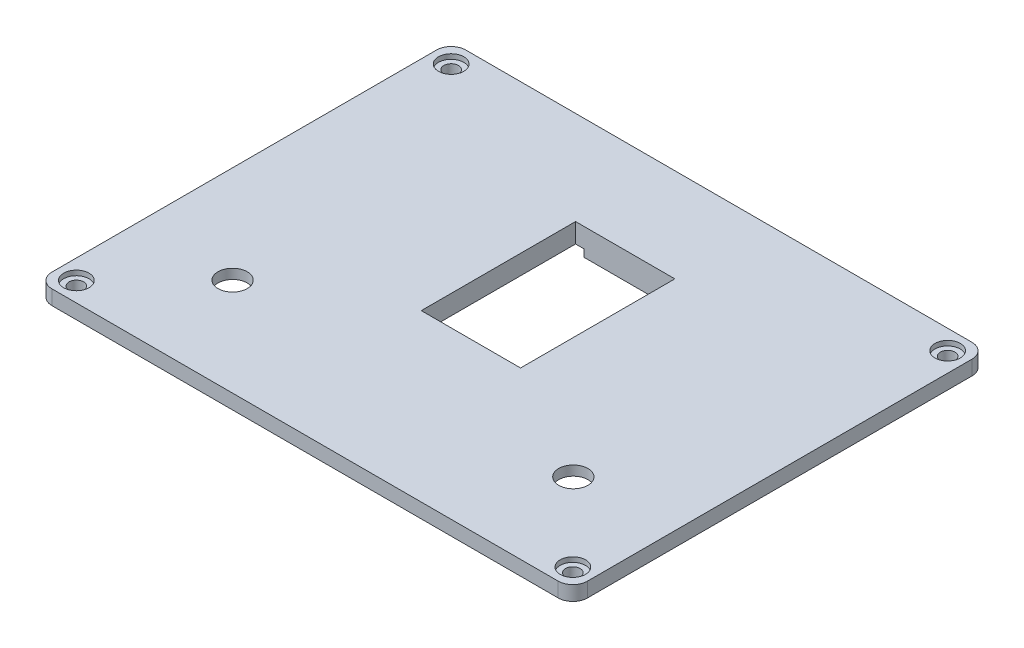
from build123d import *

# Parameters (mm, degrees)
SKETCH1_W           = 110
SKETCH1_H           = 85
BOSS_EXTRUDE1_DEPTH = 3
BOSS_EXTRUDE2_DEPTH = 1
SKETCH3_R           = 2.6
SKETCH3_R_2         = 1.5
CUT_EXTRUDE1_DEPTH  = 1
CUT_EXTRUDE2_REACH  = 6
SKETCH3_2_R         = 1.5
FILLET1_R           = 3
SKETCH15_R          = 1.75
CUT_EXTRUDE3_REACH  = 6
SKETCH17_R          = 3
SKETCH17_3_R        = 6
SKETCH17_3_R_2      = 3
CUT_EXTRUDE4_DEPTH  = 2
SKETCH18_W          = 20.4
SKETCH18_H          = 31.7
CUT_EXTRUDE5_DEPTH  = 5
SKETCH18_4_W        = 17
SKETCH18_4_H        = 5.15
BOSS_EXTRUDE3_DEPTH = 1.5
SKETCH19_R          = 1
CUT_EXTRUDE6_DEPTH  = 5
FILLET2_R           = 1


with BuildPart() as part:
    # Sketch1 → Boss-Extrude1 (new body)
    with BuildSketch(Plane(origin=(0, 0, 0), x_dir=(1, 0, 0), z_dir=(0, 1, 0))):
        with Locations((55, 42.5)):
            Rectangle(SKETCH1_W, SKETCH1_H)
    extrude(amount=BOSS_EXTRUDE1_DEPTH)

    # Sketch2 → Boss-Extrude2 (add)
    with BuildSketch(Plane.XZ):
        with BuildLine():
            ThreePointArc((100.9, -79.9), (102.071572875, -77.071572875), (104.9, -75.9))
            Line((104.9, -75.9), (104.9, -9.1))
            ThreePointArc((104.9, -9.1), (102.071572875, -7.928427125), (100.9, -5.1))
            Line((100.9, -5.1), (9.1, -5.1))
            ThreePointArc((9.1, -5.1), (7.928427125, -7.928427125), (5.1, -9.1))
            Line((5.1, -9.1), (5.1, -75.9))
            ThreePointArc((5.1, -75.9), (7.928427125, -77.071572875), (9.1, -79.9))
            Line((9.1, -79.9), (100.9, -79.9))
        make_face()
    extrude(amount=BOSS_EXTRUDE2_DEPTH)

    # Sketch3 → Cut-Extrude1 (cut)
    with BuildSketch(Plane(origin=(0, 3, 0), x_dir=(1, 0, 0), z_dir=(0, 1, 0))):
        with Locations((4, 81)):
            Circle(SKETCH3_R)
        with Locations((4, 81)):
            Circle(SKETCH3_R_2, mode=Mode.SUBTRACT)
        with Locations((106, 81)):
            Circle(SKETCH3_R)
        with Locations((106, 81)):
            Circle(SKETCH3_R_2, mode=Mode.SUBTRACT)
        with Locations((106, 4)):
            Circle(SKETCH3_R)
        with Locations((106, 4)):
            Circle(SKETCH3_R_2, mode=Mode.SUBTRACT)
        with Locations((4, 4)):
            Circle(SKETCH3_R)
        with Locations((4, 4)):
            Circle(SKETCH3_R_2, mode=Mode.SUBTRACT)
    extrude(amount=-CUT_EXTRUDE1_DEPTH, mode=Mode.SUBTRACT)

    # Sketch3_2 → Cut-Extrude2 (cut, up to next)
    with BuildSketch(Plane(origin=(0, 3, 0), x_dir=(1, 0, 0), z_dir=(0, 1, 0)), mode=Mode.PRIVATE) as cut_extrude2_sk1:
        with Locations((4, 81)):
            Circle(SKETCH3_2_R)
    cut_extrude2_tool1 = extrude(cut_extrude2_sk1.sketch, amount=-CUT_EXTRUDE2_REACH, mode=Mode.PRIVATE) & part.part
    add(cut_extrude2_tool1.solids().sort_by_distance((4, 3, -81))[0], mode=Mode.SUBTRACT)
    # Sketch3_2 → Cut-Extrude2 (cut, up to next)
    with BuildSketch(Plane(origin=(0, 3, 0), x_dir=(1, 0, 0), z_dir=(0, 1, 0)), mode=Mode.PRIVATE) as cut_extrude2_sk2:
        with Locations((106, 81)):
            Circle(SKETCH3_2_R)
    cut_extrude2_tool2 = extrude(cut_extrude2_sk2.sketch, amount=-CUT_EXTRUDE2_REACH, mode=Mode.PRIVATE) & part.part
    add(cut_extrude2_tool2.solids().sort_by_distance((106, 3, -81))[0], mode=Mode.SUBTRACT)
    # Sketch3_2 → Cut-Extrude2 (cut, up to next)
    with BuildSketch(Plane(origin=(0, 3, 0), x_dir=(1, 0, 0), z_dir=(0, 1, 0)), mode=Mode.PRIVATE) as cut_extrude2_sk3:
        with Locations((106, 4)):
            Circle(SKETCH3_2_R)
    cut_extrude2_tool3 = extrude(cut_extrude2_sk3.sketch, amount=-CUT_EXTRUDE2_REACH, mode=Mode.PRIVATE) & part.part
    add(cut_extrude2_tool3.solids().sort_by_distance((106, 3, -4))[0], mode=Mode.SUBTRACT)
    # Sketch3_2 → Cut-Extrude2 (cut, up to next)
    with BuildSketch(Plane(origin=(0, 3, 0), x_dir=(1, 0, 0), z_dir=(0, 1, 0)), mode=Mode.PRIVATE) as cut_extrude2_sk4:
        with Locations((4, 4)):
            Circle(SKETCH3_2_R)
    cut_extrude2_tool4 = extrude(cut_extrude2_sk4.sketch, amount=-CUT_EXTRUDE2_REACH, mode=Mode.PRIVATE) & part.part
    add(cut_extrude2_tool4.solids().sort_by_distance((4, 3, -4))[0], mode=Mode.SUBTRACT)

    # Fillet1
    fillet1_edges = [part.edges().sort_by_distance(p)[0] for p in [
        (0, 1.5, -85),
        (110, 1.5, -85),
        (110, 1.5, 0),
        (0, 1.5, 0),
    ]]
    fillet(fillet1_edges, radius=FILLET1_R)

    # Cut-Sweep3: sweep along a path in Sketch14
    with BuildLine(Plane.XZ) as cut_sweep3_path:
        Line((7.35, -5.1), (7.35, -3.35))
        Line((7.35, -3.35), (102.65, -3.35))
        Line((102.65, -3.35), (102.65, -5.1))
        ThreePointArc((102.65, -5.1), (103.309009742, -6.690990258), (104.9, -7.35))
        Line((104.9, -7.35), (106.65, -7.35))
        Line((106.65, -7.35), (106.65, -77.65))
        Line((106.65, -77.65), (104.9, -77.65))
        ThreePointArc((104.9, -77.65), (103.309009742, -78.309009742), (102.65, -79.9))
        Line((102.65, -79.9), (102.65, -81.65))
        Line((102.65, -81.65), (7.35, -81.65))
        Line((7.35, -81.65), (7.35, -79.9))
        ThreePointArc((7.35, -79.9), (6.690990258, -78.309009742), (5.1, -77.65))
        Line((5.1, -77.65), (3.35, -77.65))
        Line((3.35, -77.65), (3.35, -7.35))
        Line((3.35, -7.35), (5.1, -7.35))
        ThreePointArc((5.1, -7.35), (6.690990258, -6.690990258), (7.35, -5.1))
    # Sketch15 → Cut-Sweep3 (sweep, cut)
    with BuildSketch(Plane.XY.offset(-77.65)):
        with Locations((106.65, 0)):
            Circle(SKETCH15_R)
    sweep(path=cut_sweep3_path.line, transition=Transition.RIGHT, mode=Mode.SUBTRACT)

    # Sketch17 → Cut-Extrude3 (cut, up to next)
    with BuildSketch(Plane.XZ.offset(1), mode=Mode.PRIVATE) as cut_extrude3_sk1:
        with Locations((20, -20.1)):
            Circle(SKETCH17_R)
    cut_extrude3_tool1 = extrude(cut_extrude3_sk1.sketch, amount=-CUT_EXTRUDE3_REACH, mode=Mode.PRIVATE) & part.part
    add(cut_extrude3_tool1.solids().sort_by_distance((20, -1, -20.1))[0], mode=Mode.SUBTRACT)
    # Sketch17 → Cut-Extrude3 (cut, up to next)
    with BuildSketch(Plane.XZ.offset(1), mode=Mode.PRIVATE) as cut_extrude3_sk2:
        with Locations((90, -20.1)):
            Circle(SKETCH17_R)
    cut_extrude3_tool2 = extrude(cut_extrude3_sk2.sketch, amount=-CUT_EXTRUDE3_REACH, mode=Mode.PRIVATE) & part.part
    add(cut_extrude3_tool2.solids().sort_by_distance((90, -1, -20.1))[0], mode=Mode.SUBTRACT)

    # Sketch17_3 → Cut-Extrude4 (cut)
    with BuildSketch(Plane.XZ.offset(1)):
        with Locations((90, -20.1)):
            Circle(SKETCH17_3_R)
        with Locations((90, -20.1)):
            Circle(SKETCH17_3_R_2, mode=Mode.SUBTRACT)
        with Locations((20, -20.1)):
            Circle(SKETCH17_3_R)
        with Locations((20, -20.1)):
            Circle(SKETCH17_3_R_2, mode=Mode.SUBTRACT)
    extrude(amount=-CUT_EXTRUDE4_DEPTH, mode=Mode.SUBTRACT)

    # Sketch18 → Cut-Extrude5 (cut, through all)
    with BuildSketch(Plane.XZ.offset(1)):
        with Locations((55, -49.908642181)):
            Rectangle(SKETCH18_W, SKETCH18_H)
    extrude(amount=-CUT_EXTRUDE5_DEPTH, mode=Mode.SUBTRACT)

    # Sketch18_4 → Boss-Extrude3 (add)
    with BuildSketch(Plane.XZ.offset(1)):
        with Locations((55, -31.483642181)):
            Rectangle(SKETCH18_4_W, SKETCH18_4_H)
        with Locations((55, -68.333642181)):
            Rectangle(SKETCH18_4_W, SKETCH18_4_H)
    extrude(amount=BOSS_EXTRUDE3_DEPTH)

    # Sketch19 → Cut-Extrude6 (cut)
    with BuildSketch(Plane.XZ.offset(2.5)):
        with Locations((55, -31.908642181)):
            Circle(SKETCH19_R)
        with Locations((55, -67.908642181)):
            Circle(SKETCH19_R)
    extrude(amount=-CUT_EXTRUDE6_DEPTH, mode=Mode.SUBTRACT)

    # Fillet2
    fillet2_edges = [part.edges().sort_by_distance(p)[0] for p in [
        (63.5, -1.75, -28.908642181),
        (46.5, -1.75, -28.908642181),
        (46.5, -1.75, -70.908642181),
        (63.5, -1.75, -70.908642181),
    ]]
    fillet(fillet2_edges, radius=FILLET2_R)


solid = part.part
